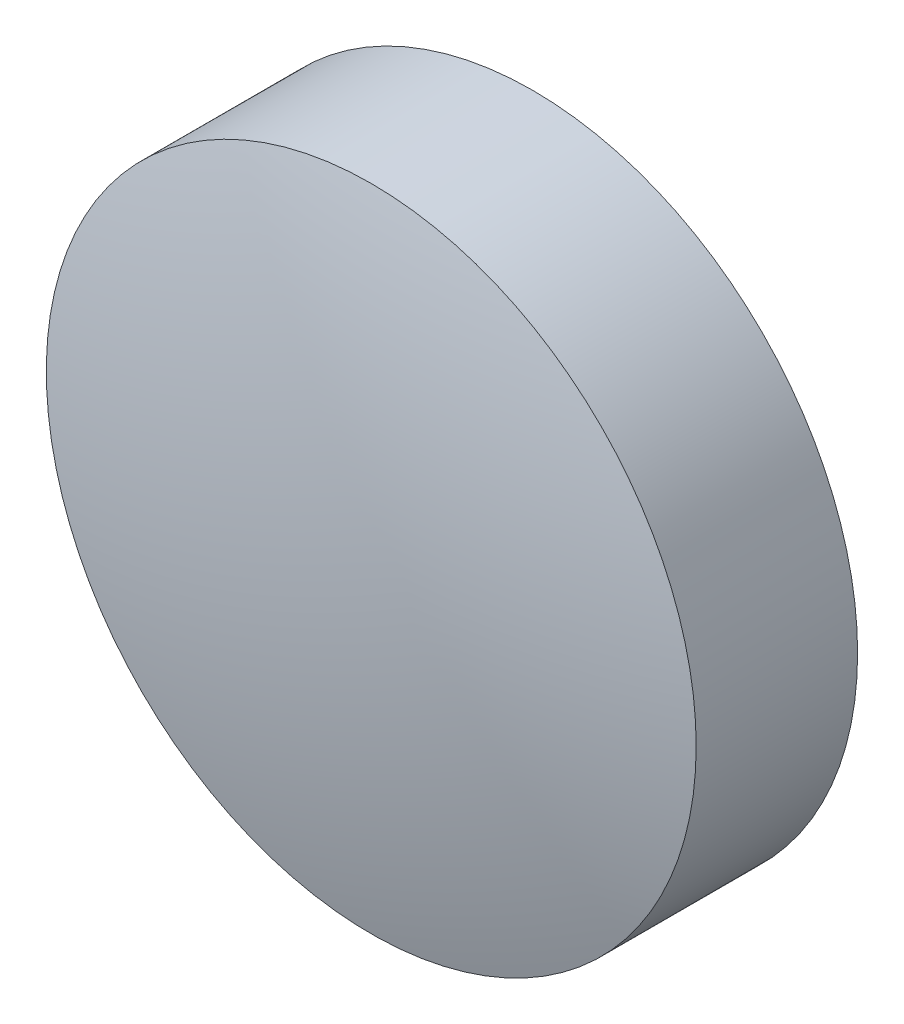
from build123d import *


with BuildPart() as part:
    # Skica1 → Rotovat1 (revolve)
    with BuildSketch(Plane(origin=(0, 0, 0), x_dir=(0, 0, -1), z_dir=(1, 0, 0))):
        with BuildLine():
            Line((-1.331796606, 6.25), (1.77303265, 6.25))
            ThreePointArc((1.77303265, 6.25), (2.055672608, 3.130679015), (2.15, 0))
            Line((2.15, 0), (-2.15, 0))
            ThreePointArc((-2.15, 0), (-1.944580179, 3.151664512), (-1.331796606, 6.25))
        make_face()
    revolve(axis=Axis((0, 0, 65.353876671), (0, 0, -1)))


solid = part.part
